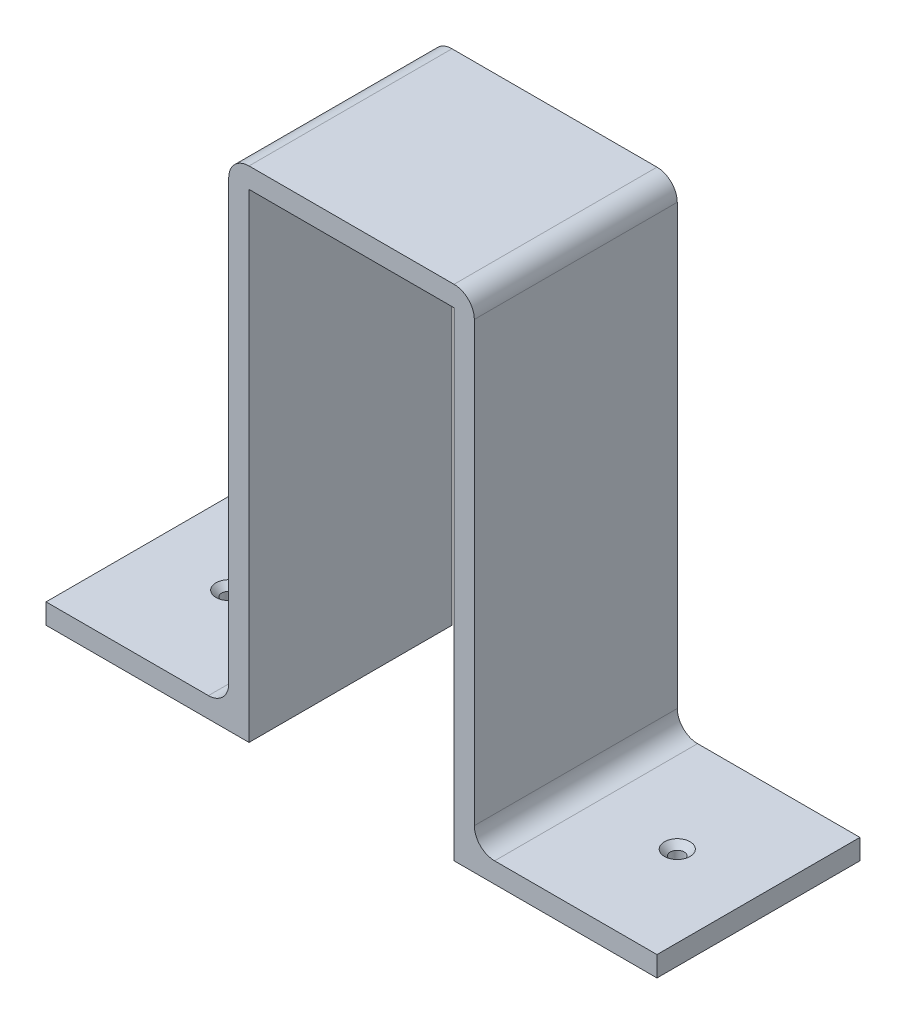
from build123d import *

# Parameters (mm, degrees)
BOSS_EXTRU_1_DEPTH                             = 50
CONG_1_R                                       = 5
FRAISAGE_POUR_VIS_T_TE_FRAIS_E_M31_D           = 3.4
FRAISAGE_POUR_VIS_T_TE_FRAIS_E_M31_CSINK_D     = 6.3
FRAISAGE_POUR_VIS_T_TE_FRAIS_E_M31_CSINK_ANGLE = 90


with BuildPart() as part:
    # Esquisse1 → Boss.-Extru.1 (new body)
    with BuildSketch(Plane.XY):
        Polygon((-25.25, 0), (25.25, 0), (25.25, -118), (75.25, -118), (75.25, -113), (30.25, -113), (30.25, 5), (-30.25, 5), (-30.25, -113), (-75.25, -113), (-75.25, -118), (-25.25, -118), align=None)
    extrude(amount=BOSS_EXTRU_1_DEPTH)

    # Congé1
    cong_1_edges = [part.edges().sort_by_distance(p)[0] for p in [
        (-30.25, -113, 25),
        (-30.25, 5, 25),
        (30.25, 5, 25),
        (30.25, -113, 25),
    ]]
    fillet(cong_1_edges, radius=CONG_1_R)

    # Fraisage pour vis à tête fraisée M31 (through all)
    with Locations(Plane(origin=(0, -113, 0), x_dir=(1, 0, 0), z_dir=(0, 1, 0))):
        with Locations((-55.25, -25), (55.25, -25)):
            CounterSinkHole(FRAISAGE_POUR_VIS_T_TE_FRAIS_E_M31_D / 2, FRAISAGE_POUR_VIS_T_TE_FRAIS_E_M31_CSINK_D / 2, counter_sink_angle=FRAISAGE_POUR_VIS_T_TE_FRAIS_E_M31_CSINK_ANGLE)


solid = part.part
